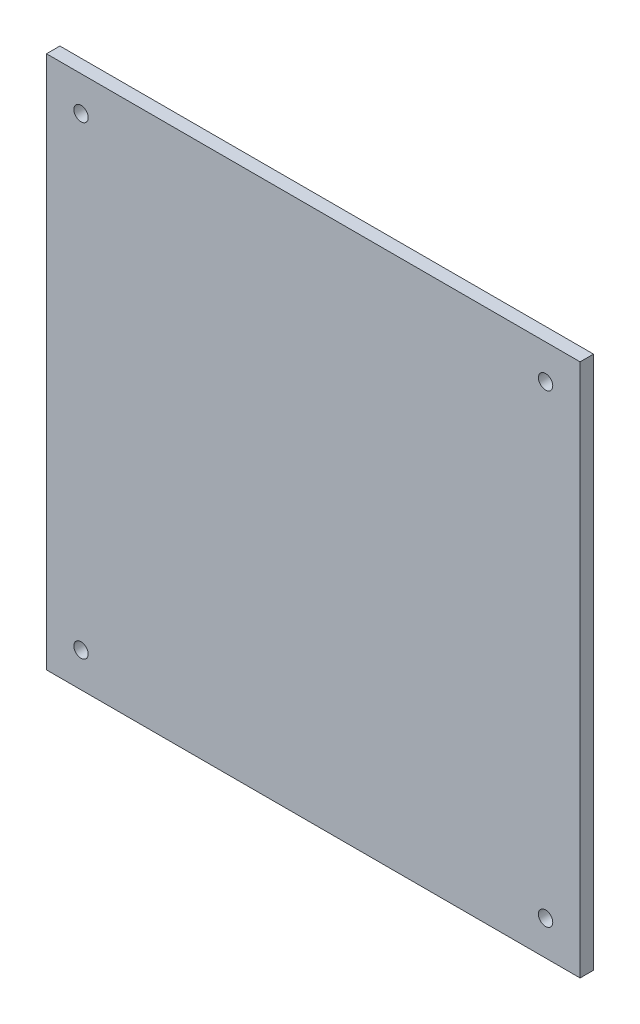
from build123d import *

# Parameters (mm, degrees)
SKETCH1_W           = 126.35
SKETCH1_H           = 126.35
BOSS_EXTRUDE1_DEPTH = 3.175
SKETCH3_R           = 1.7
CUT_EXTRUDE2_DEPTH  = 3.175


with BuildPart() as part:
    # Sketch1 → Boss-Extrude1 (new body)
    with BuildSketch(Plane.XY):
        Rectangle(SKETCH1_W, SKETCH1_H)
    extrude(amount=BOSS_EXTRUDE1_DEPTH)

    # Sketch3 → Cut-Extrude2 (cut)
    with BuildSketch(Plane(origin=(-17.047760395, -31.681970197, 3.175), x_dir=(1, 0, 0), z_dir=(0, 0, 1))):
        with Locations((-37.952239605, 86.681970197)):
            Circle(SKETCH3_R)
        with Locations((-37.952239605, -23.318029803)):
            Circle(SKETCH3_R)
        with Locations((72.047760395, -23.318029803)):
            Circle(SKETCH3_R)
        with Locations((72.047760395, 86.681970197)):
            Circle(SKETCH3_R)
    extrude(amount=-CUT_EXTRUDE2_DEPTH, mode=Mode.SUBTRACT)


solid = part.part
